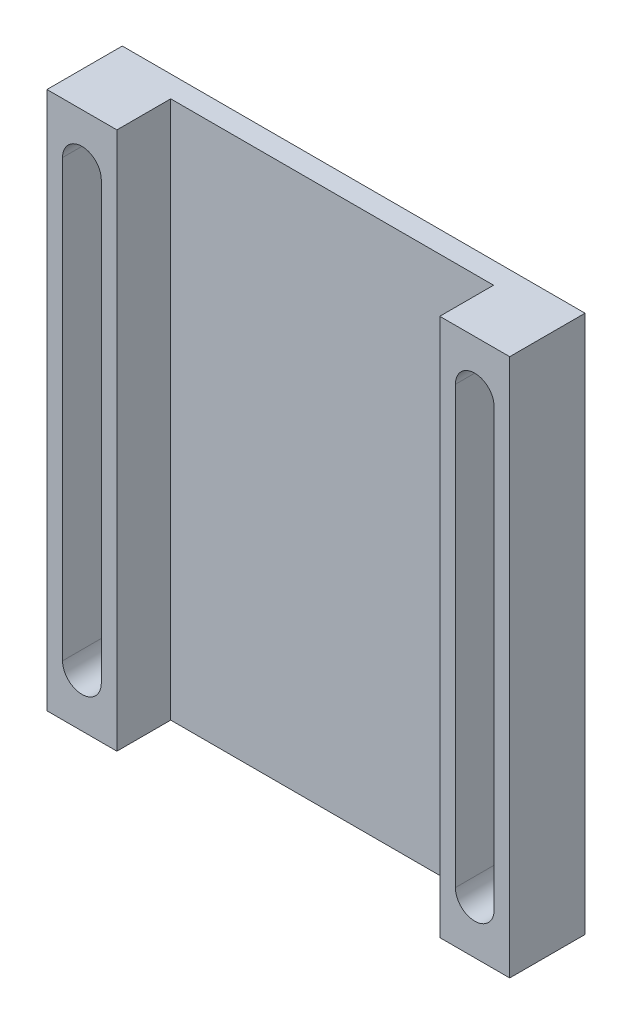
from build123d import *

# Parameters (mm, degrees)
SKETCH1_W           = 300
SKETCH1_H           = 500
BOSS_EXTRUDE1_DEPTH = 20
SKETCH1_3_W         = 65
SKETCH1_3_H         = 500
BOSS_EXTRUDE2_DEPTH = 70
CUT_EXTRUDE1_START  = 70
CUT_EXTRUDE1_DEPTH  = 47


with BuildPart() as part:
    # Sketch1 → Boss-Extrude1 (new body)
    with BuildSketch(Plane.XY):
        Rectangle(SKETCH1_W, SKETCH1_H)
    extrude(amount=BOSS_EXTRUDE1_DEPTH)

    # Sketch1_3 → Boss-Extrude2 (add)
    with BuildSketch(Plane.XY):
        with Locations((182.5, 0)):
            Rectangle(SKETCH1_3_W, SKETCH1_3_H)
        with Locations((-182.5, 0)):
            Rectangle(SKETCH1_3_W, SKETCH1_3_H)
    extrude(amount=BOSS_EXTRUDE2_DEPTH)

    # Sketch1_5 → Cut-Extrude1 (cut)
    with BuildSketch(Plane.XY.offset(CUT_EXTRUDE1_START)):
        with BuildLine():
            Line((-164.5, 202.5), (-164.5, -202.5))
            ThreePointArc((-164.5, -202.5), (-182.5, -220.5), (-200.5, -202.5))
            Line((-200.5, -202.5), (-200.5, 202.5))
            ThreePointArc((-200.5, 202.5), (-182.5, 220.5), (-164.5, 202.5))
        make_face()
        with BuildLine():
            Line((164.5, 202.5), (164.5, -202.5))
            ThreePointArc((164.5, -202.5), (182.5, -220.5), (200.5, -202.5))
            Line((200.5, -202.5), (200.5, 202.5))
            ThreePointArc((200.5, 202.5), (182.5, 220.5), (164.5, 202.5))
        make_face()
    extrude(amount=-CUT_EXTRUDE1_DEPTH, mode=Mode.SUBTRACT)


solid = part.part
